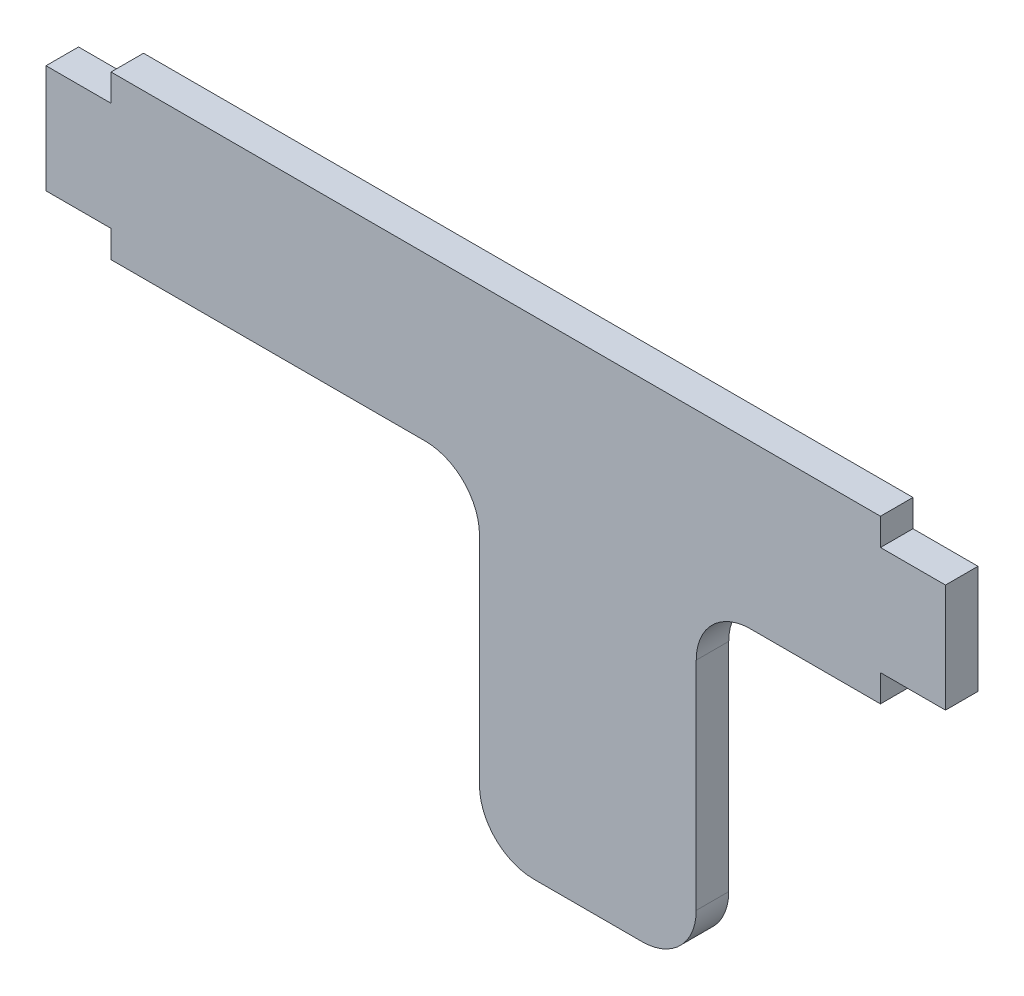
from build123d import *

# Parameters (mm, degrees)
ESBO_O1_W                = 71
ESBO_O1_H                = 15
ESBO_O1_W_2              = 20
ESBO_O1_H_2              = 30
ESBO_O1_W_3              = 6
ESBO_O1_H_3              = 10
RESSALTO_EXTRUS_O1_DEPTH = 3
FILETE1_R                = 5


with BuildPart() as part:
    # Esboço1 → Ressalto-extrusão1 (new body)
    with BuildSketch(Plane.XY):
        Rectangle(ESBO_O1_W, ESBO_O1_H)
        with Locations((8.5, -22.5)):
            Rectangle(ESBO_O1_W_2, ESBO_O1_H_2)
        with Locations((38.5, 0)):
            Rectangle(ESBO_O1_W_3, ESBO_O1_H_3)
        with Locations((-38.5, 0)):
            Rectangle(ESBO_O1_W_3, ESBO_O1_H_3)
    extrude(amount=RESSALTO_EXTRUS_O1_DEPTH)

    # Filete1
    filete1_edges = [part.edges().sort_by_distance(p)[0] for p in [
        (18.5, -7.5, 1.5),
        (18.5, -37.5, 1.5),
        (-1.5, -37.5, 1.5),
        (-1.5, -7.5, 1.5),
    ]]
    fillet(filete1_edges, radius=FILETE1_R)


solid = part.part
